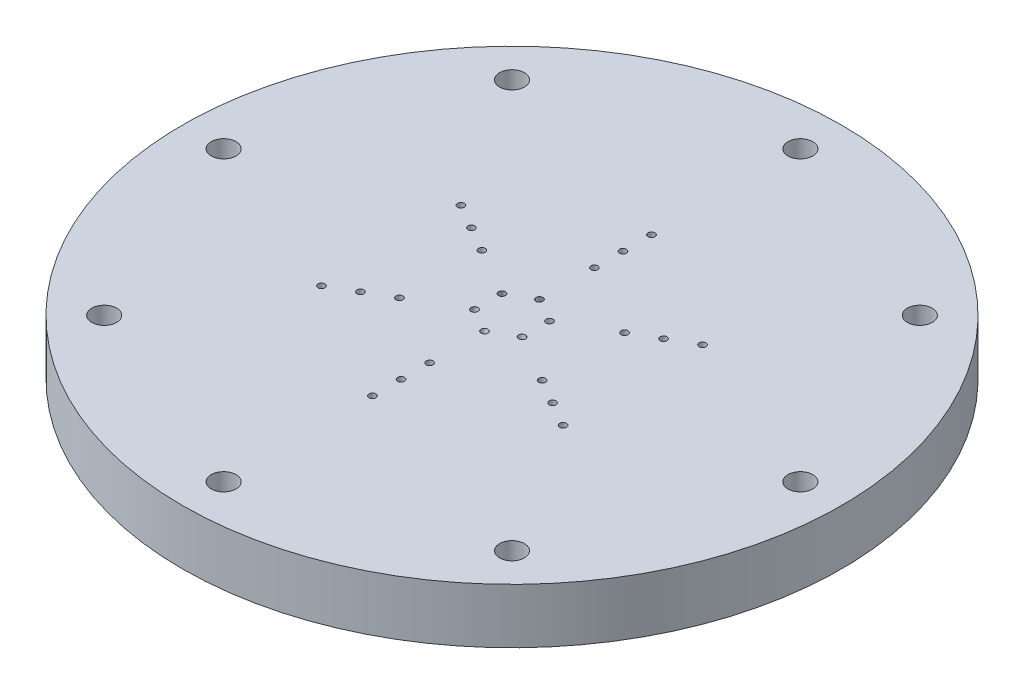
from build123d import *

# Parameters (mm, degrees)
SKETCH1_R                                      = 38.1
BOSS_EXTRUDE1_DEPTH                            = 6.35
CBORE_FOR_4_BUTTON_HEAD_CAP_SCREW1_D           = 2.8702
CBORE_FOR_4_BUTTON_HEAD_CAP_SCREW1_CBORE_D     = 4.826
CBORE_FOR_4_BUTTON_HEAD_CAP_SCREW1_CBORE_DEPTH = 1.905
CIRPATTERN1_COUNT                              = 8
SKETCH6_R                                      = 0.396875
CUT_EXTRUDE1_DEPTH                             = 7.35
SKETCH7_R                                      = 0.396875
CIRPATTERN2_COUNT                              = 6


with BuildPart() as part:
    # Sketch1 → Boss-Extrude1 (new body)
    with BuildSketch(Plane(origin=(0, 0, 0), x_dir=(1, 0, 0), z_dir=(0, 1, 0))):
        Circle(SKETCH1_R)
    extrude(amount=BOSS_EXTRUDE1_DEPTH)

    # CBORE for #4 Button Head Cap Screw1 (through all)
    with Locations(Plane(origin=(0, 0, 0), x_dir=(-1, 0, 0), z_dir=(0, -1, 0))):
        with Locations((0, -33.3375)):
            cbore_for_4_button_head_cap_screw1 = CounterBoreHole(CBORE_FOR_4_BUTTON_HEAD_CAP_SCREW1_D / 2, CBORE_FOR_4_BUTTON_HEAD_CAP_SCREW1_CBORE_D / 2, CBORE_FOR_4_BUTTON_HEAD_CAP_SCREW1_CBORE_DEPTH)

    # CirPattern1: CBORE for #4 Button Head Cap Screw1 ×8 about axis
    cirpattern1_axis = Axis((0, 0, 0), (0, 1, 0))
    for i in range(1, CIRPATTERN1_COUNT):
        add(cbore_for_4_button_head_cap_screw1.rotate(cirpattern1_axis, i * 360 / CIRPATTERN1_COUNT), mode=Mode.SUBTRACT)

    # Sketch6 → Cut-Extrude1 (cut, through all)
    with BuildSketch(Plane(origin=(0, 6.35, 0), x_dir=(1, 0, 0), z_dir=(0, 1, 0))):
        with Locations((0, 9.525)):
            Circle(SKETCH6_R)
        with Locations((0, 12.827)):
            Circle(SKETCH6_R)
        with Locations((0, 16.129)):
            Circle(SKETCH6_R)
        with Locations((8.248891971, 4.7625)):
            Circle(SKETCH6_R)
        with Locations((11.108507854, 6.4135)):
            Circle(SKETCH6_R)
        with Locations((13.968123738, 8.0645)):
            Circle(SKETCH6_R)
        with Locations((8.248891971, -4.7625)):
            Circle(SKETCH6_R)
        with Locations((11.108507854, -6.4135)):
            Circle(SKETCH6_R)
        with Locations((13.968123738, -8.0645)):
            Circle(SKETCH6_R)
        with Locations((0, -9.525)):
            Circle(SKETCH6_R)
        with Locations((0, -12.827)):
            Circle(SKETCH6_R)
        with Locations((0, -16.129)):
            Circle(SKETCH6_R)
        with Locations((-8.248891971, -4.7625)):
            Circle(SKETCH6_R)
        with Locations((-11.108507854, -6.4135)):
            Circle(SKETCH6_R)
        with Locations((-13.968123738, -8.0645)):
            Circle(SKETCH6_R)
        with Locations((-8.248891971, 4.7625)):
            Circle(SKETCH6_R)
        with Locations((-11.108507854, 6.4135)):
            Circle(SKETCH6_R)
        with Locations((-13.968123738, 8.0645)):
            Circle(SKETCH6_R)
    extrude(amount=-CUT_EXTRUDE1_DEPTH, mode=Mode.SUBTRACT)

    # Cut-Sweep1: sweep along a curve in space
    with BuildLine() as cut_sweep1_path:
        Line((0, 6.35, -3.175), (0, 0, -4.7625))
    # Sketch7 → Cut-Sweep1 (sweep, cut)
    with BuildSketch(Plane(origin=(0, 6.35, 0), x_dir=(1, 0, 0), z_dir=(0, 1, 0))):
        with Locations((0, 3.175)):
            Circle(SKETCH7_R)
    cut_sweep1 = sweep(path=cut_sweep1_path.line, mode=Mode.SUBTRACT)

    # CirPattern2: Cut-Sweep1 ×6 about axis
    cirpattern2_axis = Axis((0, 6.35, 0), (0, 1, 0))
    for i in range(1, CIRPATTERN2_COUNT):
        add(cut_sweep1.rotate(cirpattern2_axis, i * 360 / CIRPATTERN2_COUNT), mode=Mode.SUBTRACT)


solid = part.part
